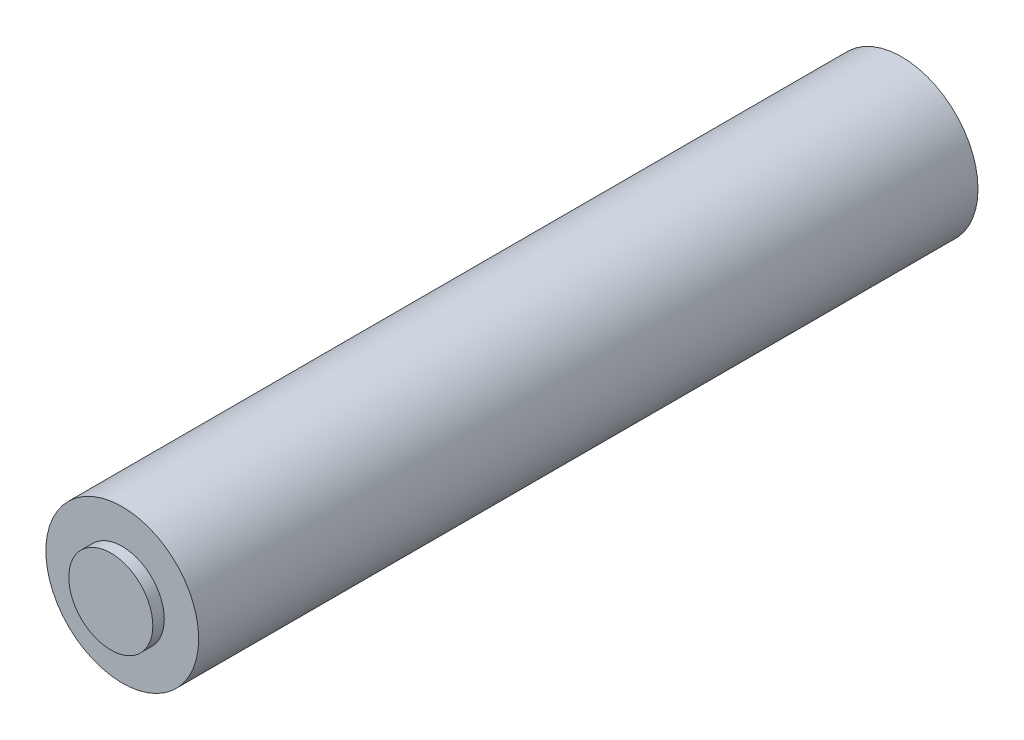
from build123d import *

# Parameters (mm, degrees)
CROQUIS1_R                   = 10
SALIENTE_EXTRUIR2_DEPTH      = 102
CROQUIS2_R                   = 5.5
SALIENTE_EXTRUIR3_DEPTH      = 1.5
SALIENTE_EXTRUIR3_DEPTH_BACK = 103.5


with BuildPart() as part:
    # Croquis1 → Saliente-Extruir2 (new body)
    with BuildSketch(Plane.XY):
        Circle(CROQUIS1_R)
    extrude(amount=SALIENTE_EXTRUIR2_DEPTH)

    # Croquis2 → Saliente-Extruir3 (add, two sides)
    with BuildSketch(Plane.XY.offset(102)) as saliente_extruir3_sk:
        Circle(CROQUIS2_R)
    extrude(amount=SALIENTE_EXTRUIR3_DEPTH)
    extrude(saliente_extruir3_sk.sketch, amount=-SALIENTE_EXTRUIR3_DEPTH_BACK)


solid = part.part
